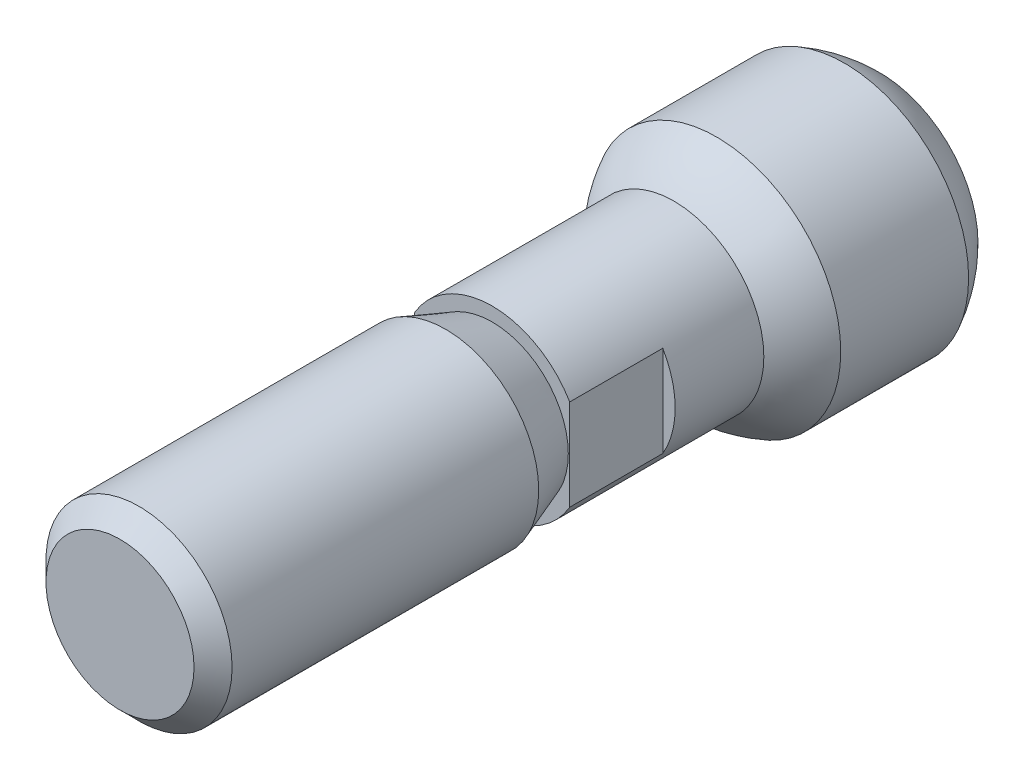
from build123d import *

# Parameters (mm, degrees)
SCHNITT_LINEAR_AUSTRAGEN1_DEPTH      = 3
SCHNITT_LINEAR_AUSTRAGEN1_DEPTH_BACK = 3


with BuildPart() as part:
    # Skizze1 → Rotation1 (revolve)
    with BuildSketch(Plane(origin=(0, 0, 0), x_dir=(1, 0, 0), z_dir=(0, 1, 0))):
        with BuildLine():
            Line((0, 0), (-2.9, 0))
            Line((-2.9, 0), (-2.9, 5.859069893))
            ThreePointArc((-2.9, 5.859069893), (-3.518262416, 6.494321905), (-4, 7.238447187))
            Line((-4, 7.238447187), (-4, 11.361552813))
            ThreePointArc((-4, 11.361552813), (-3.626876384, 11.963788222), (-3.163858404, 12.5))
            Line((-3.163858404, 12.5), (0, 12.5))
            Line((0, 12.5), (0, 0))
        make_face()
    revolve(axis=Axis((0, 0, -12.5), (0, 0, 1)))

    # Skizze2 → Schnitt-Linear austragen1 (cut, two sides: drawn at the far end of the back side and taken through both)
    with BuildSketch(Plane.XY.offset(-SCHNITT_LINEAR_AUSTRAGEN1_DEPTH_BACK)):
        Polygon((6, 4), (2.5, 4), (2.5, -5), (-2.5, -5), (-2.5, 4), (-6, 4), (-6, -6), (6, -6), align=None)
    extrude(amount=SCHNITT_LINEAR_AUSTRAGEN1_DEPTH + SCHNITT_LINEAR_AUSTRAGEN1_DEPTH_BACK, mode=Mode.SUBTRACT)

    # Skizze3 → Rotation2 (revolve)
    with BuildSketch(Plane(origin=(0, 0, 0), x_dir=(1, 0, 0), z_dir=(0, 1, 0))):
        Polygon((0, -12), (-2.3865, -12), (-3, -11.3865), (-3, -1.5), (-2.454044649, 0), (0, 0), align=None)
    revolve(axis=Axis((0, 0, 0), (0, 0, 1)))


solid = part.part
